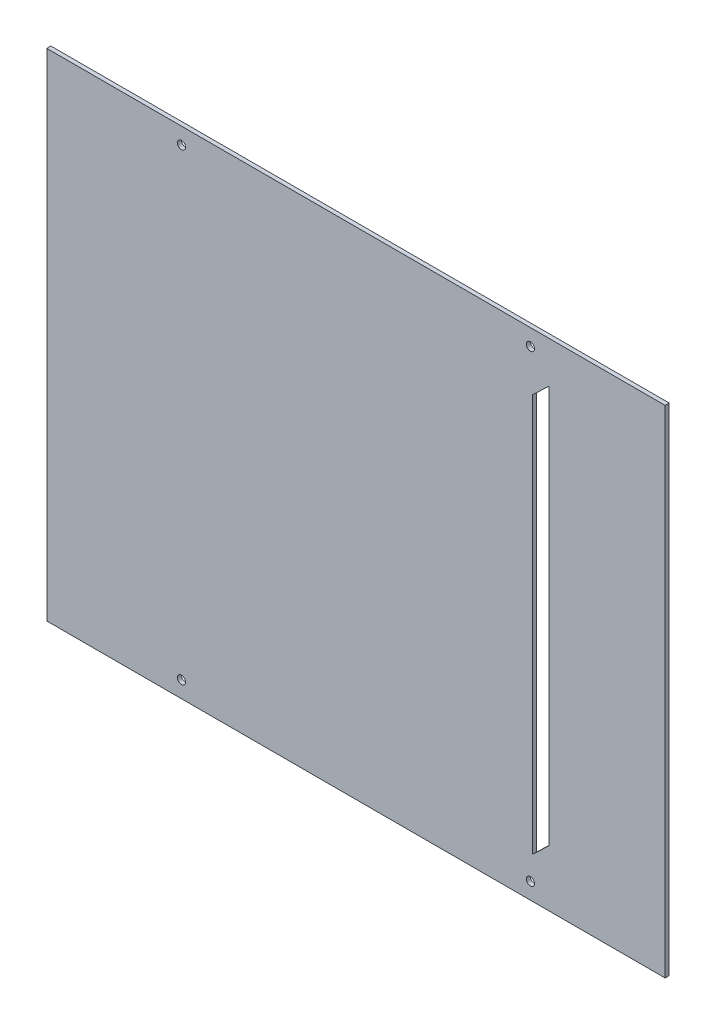
from build123d import *

# Parameters (mm, degrees)
SKETCH1_W           = 303
SKETCH1_H           = 243
SKETCH1_R           = 2
BOSS_EXTRUDE1_DEPTH = 2


with BuildPart() as part:
    # Sketch1 → Boss-Extrude1 (new body)
    with BuildSketch(Plane.XY):
        Rectangle(SKETCH1_W, SKETCH1_H)
        with Locations((85.5, -113.48019802)):
            Circle(SKETCH1_R, mode=Mode.SUBTRACT)
        with Locations((85.5, 113.48019802)):
            Circle(SKETCH1_R, mode=Mode.SUBTRACT)
        with Locations((-85.5, 113.48019802)):
            Circle(SKETCH1_R, mode=Mode.SUBTRACT)
        with Locations((-85.5, -113.48019802)):
            Circle(SKETCH1_R, mode=Mode.SUBTRACT)
        Polygon((94.5, -93.92192355), (86.5, -101.5), (86.5, -96.5), (86.5, 93.5), (94.5, 101.07807645), (94.5, 93.5), align=None, mode=Mode.SUBTRACT)
    extrude(amount=BOSS_EXTRUDE1_DEPTH)


solid = part.part
